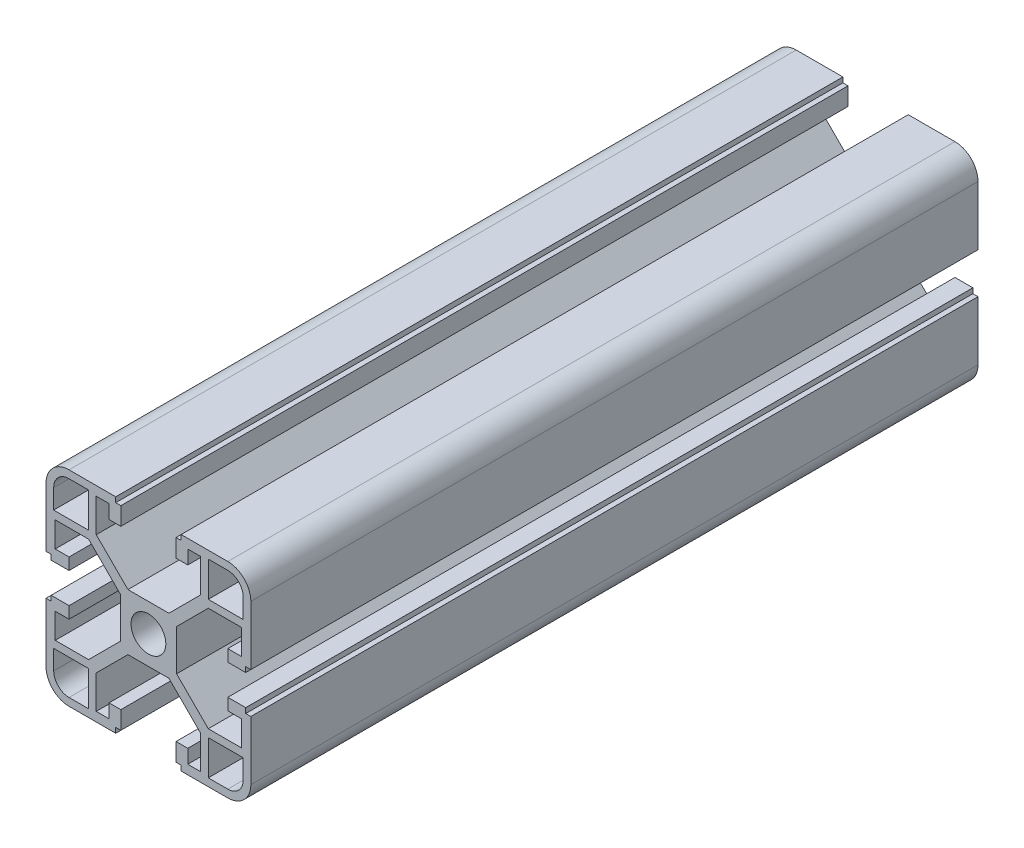
from build123d import *

# Parameters (mm, degrees)
BOSS_EXTRUDE1_DEPTH  = 142
MIRROR3_COPY_1_DEPTH = 142
MIRROR3_COPY_2_DEPTH = 142


with BuildPart() as part:
    # Sketch1 → Boss-Extrude1 (new body)
    with BuildSketch(Plane.XY):
        with BuildLine():
            Line((3.4, 0), (5.5, 0))
            Line((5.5, 0), (5.5, 4))
            Line((5.5, 4), (11.69, 10.19))
            Line((11.69, 10.19), (18.2, 10.19))
            Line((18.2, 10.19), (18.2, 5.265595036))
            Line((18.2, 5.265595036), (15.5, 5.265595036))
            Line((15.5, 5.265595036), (15.5, 2.965595036))
            Line((15.5, 2.965595036), (19, 2.965595036))
            Line((19, 2.965595036), (19, 3.965595036))
            Line((19, 3.965595036), (20, 3.965595036))
            Line((20, 3.965595036), (20, 15.5))
            ThreePointArc((20, 15.5), (18.681980515, 18.681980515), (15.5, 20))
            Line((15.5, 20), (6.385304712, 20))
            Line((6.385304712, 20), (6.385304712, 19))
            Line((6.385304712, 19), (5.385304712, 19))
            Line((5.385304712, 19), (5.385304712, 15.5))
            Line((5.385304712, 15.5), (7.685304712, 15.5))
            Line((7.685304712, 15.5), (7.685304712, 18.2))
            Line((7.685304712, 18.2), (10.19, 18.2))
            Line((10.19, 18.2), (10.19, 11.69))
            Line((10.19, 11.69), (4, 5.5))
            Line((4, 5.5), (0, 5.5))
            Line((0, 5.5), (0, 3.4))
            ThreePointArc((0, 3.4), (2.404163056, 2.404163056), (3.4, 0))
        make_face()
        with BuildLine():
            Line((18.5, 11.69), (18.5, 15.5))
            ThreePointArc((18.5, 15.5), (17.621320344, 17.621320344), (15.5, 18.5))
            Line((15.5, 18.5), (11.69, 18.5))
            Line((11.69, 18.5), (11.69, 11.69))
            Line((11.69, 11.69), (18.5, 11.69))
        make_face(mode=Mode.SUBTRACT)
    boss_extrude1 = extrude(amount=BOSS_EXTRUDE1_DEPTH)

    # Mirror1: Boss-Extrude1 across plane
    add(boss_extrude1.mirror(Plane.ZX))

    # Mirror2: Boss-Extrude1 across plane
    add(boss_extrude1.mirror(Plane(origin=(0, 0, 0), x_dir=(0, 0, 1), z_dir=(1, 0, 0))))

    # Mirror3 copy 1 sketch → Mirror3 copy 1 (add)
    with BuildSketch(Plane(origin=(0, 0, 0), x_dir=(-1, 0, 0), z_dir=(0, 0, 1))):
        with BuildLine():
            Line((3.4, 0), (5.5, 0))
            Line((5.5, 0), (5.5, 4))
            Line((5.5, 4), (11.69, 10.19))
            Line((11.69, 10.19), (18.2, 10.19))
            Line((18.2, 10.19), (18.2, 5.265595036))
            Line((18.2, 5.265595036), (15.5, 5.265595036))
            Line((15.5, 5.265595036), (15.5, 2.965595036))
            Line((15.5, 2.965595036), (19, 2.965595036))
            Line((19, 2.965595036), (19, 3.965595036))
            Line((19, 3.965595036), (20, 3.965595036))
            Line((20, 3.965595036), (20, 15.5))
            ThreePointArc((20, 15.5), (18.681980515, 18.681980515), (15.5, 20))
            Line((15.5, 20), (6.385304712, 20))
            Line((6.385304712, 20), (6.385304712, 19))
            Line((6.385304712, 19), (5.385304712, 19))
            Line((5.385304712, 19), (5.385304712, 15.5))
            Line((5.385304712, 15.5), (7.685304712, 15.5))
            Line((7.685304712, 15.5), (7.685304712, 18.2))
            Line((7.685304712, 18.2), (10.19, 18.2))
            Line((10.19, 18.2), (10.19, 11.69))
            Line((10.19, 11.69), (4, 5.5))
            Line((4, 5.5), (0, 5.5))
            Line((0, 5.5), (0, 3.4))
            ThreePointArc((0, 3.4), (2.404163056, 2.404163056), (3.4, 0))
        make_face()
        with BuildLine():
            Line((18.5, 11.69), (18.5, 15.5))
            ThreePointArc((18.5, 15.5), (17.621320344, 17.621320344), (15.5, 18.5))
            Line((15.5, 18.5), (11.69, 18.5))
            Line((11.69, 18.5), (11.69, 11.69))
            Line((11.69, 11.69), (18.5, 11.69))
        make_face(mode=Mode.SUBTRACT)
    extrude(amount=MIRROR3_COPY_1_DEPTH)

    # Mirror3 copy 2 sketch → Mirror3 copy 2 (add)
    with BuildSketch(Plane.XY):
        with BuildLine():
            Line((3.4, 0), (5.5, 0))
            Line((5.5, 0), (5.5, -4))
            Line((5.5, -4), (11.69, -10.19))
            Line((11.69, -10.19), (18.2, -10.19))
            Line((18.2, -10.19), (18.2, -5.265595036))
            Line((18.2, -5.265595036), (15.5, -5.265595036))
            Line((15.5, -5.265595036), (15.5, -2.965595036))
            Line((15.5, -2.965595036), (19, -2.965595036))
            Line((19, -2.965595036), (19, -3.965595036))
            Line((19, -3.965595036), (20, -3.965595036))
            Line((20, -3.965595036), (20, -15.5))
            ThreePointArc((20, -15.5), (18.681980515, -18.681980515), (15.5, -20))
            Line((15.5, -20), (6.385304712, -20))
            Line((6.385304712, -20), (6.385304712, -19))
            Line((6.385304712, -19), (5.385304712, -19))
            Line((5.385304712, -19), (5.385304712, -15.5))
            Line((5.385304712, -15.5), (7.685304712, -15.5))
            Line((7.685304712, -15.5), (7.685304712, -18.2))
            Line((7.685304712, -18.2), (10.19, -18.2))
            Line((10.19, -18.2), (10.19, -11.69))
            Line((10.19, -11.69), (4, -5.5))
            Line((4, -5.5), (0, -5.5))
            Line((0, -5.5), (0, -3.4))
            ThreePointArc((0, -3.4), (2.404163056, -2.404163056), (3.4, 0))
        make_face()
        with BuildLine():
            Line((18.5, -11.69), (18.5, -15.5))
            ThreePointArc((18.5, -15.5), (17.621320344, -17.621320344), (15.5, -18.5))
            Line((15.5, -18.5), (11.69, -18.5))
            Line((11.69, -18.5), (11.69, -11.69))
            Line((11.69, -11.69), (18.5, -11.69))
        make_face(mode=Mode.SUBTRACT)
    extrude(amount=MIRROR3_COPY_2_DEPTH)


solid = part.part
